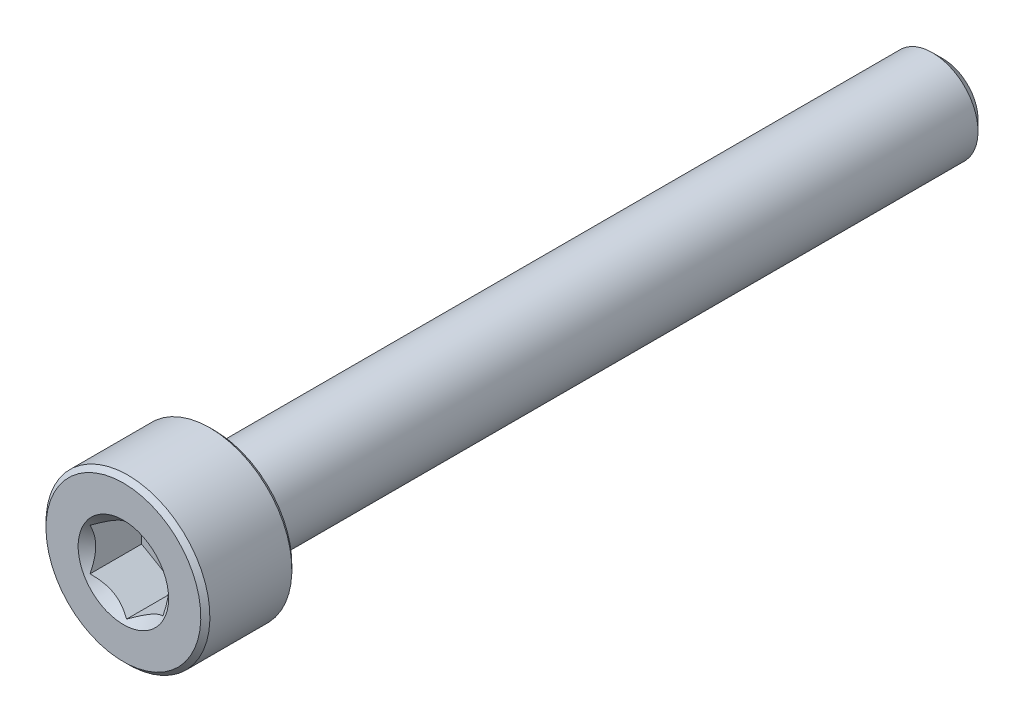
from build123d import *

# Parameters (mm, degrees)
CUT_EXTRUDE1_DEPTH = 1.5
SKETCH4_R          = 1.241303079
CUT_EXTRUDE2_DEPTH = 1.5
CUT_EXTRUDE2_DRAFT = -45


with BuildPart() as part:
    # Sketch2 → Revolve1 (revolve)
    with BuildSketch(Plane(origin=(0, 0, 0), x_dir=(0, 0, -1), z_dir=(1, 0, 0))):
        with BuildLine():
            Line((-11.25, 0), (-11.25, 2.125))
            Line((-11.25, 2.125), (-11.125, 2.25))
            Line((-11.125, 2.25), (-8.875, 2.25))
            Line((-8.875, 2.25), (-8.75, 2.125))
            Line((-8.75, 2.125), (-8.75, 1.375))
            ThreePointArc((-8.75, 1.375), (-8.713388348, 1.286611652), (-8.625, 1.25))
            Line((-8.625, 1.25), (10.957716426, 1.25))
            Line((10.957716426, 1.25), (11.25, 0.957716426))
            Line((11.25, 0.957716426), (11.25, 0))
            Line((11.25, 0), (-11.25, 0))
        make_face()
    revolve(axis=Axis((0, 0, -11.25), (0, 0, 1)))

    # Sketch3 → Cut-Extrude1 (cut)
    with BuildSketch(Plane.XY.offset(11.25)):
        Polygon((1, -0.577350269), (1, 0.577350269), (0, 1.154700538), (-1, 0.577350269), (-1, -0.577350269), (0, -1.154700538), align=None)
    extrude(amount=-CUT_EXTRUDE1_DEPTH, mode=Mode.SUBTRACT)


with BuildPart() as cut_extrude2_tool:
    # Sketch4 → Cut-Extrude2 (with draft: the straight prism first)
    with BuildSketch(Plane.XY.offset(11.25)):
        Circle(SKETCH4_R)
    extrude(amount=-CUT_EXTRUDE2_DEPTH)
    # Cut-Extrude2: the draft: its side faces are tilted about the plane it starts from
    cut_extrude2_sides = [cut_extrude2_tool.faces().sort_by_distance(p)[0] for p in [
        (-1.241303079, 0, 10.5),
    ]]
    draft(cut_extrude2_sides, Plane.XY.offset(11.25), CUT_EXTRUDE2_DRAFT)


with BuildPart() as part_1:
    add(part.part)

    # Cut-Extrude2: cut by cut_extrude2_tool
    add(cut_extrude2_tool.part, mode=Mode.SUBTRACT)


solid = part_1.part
